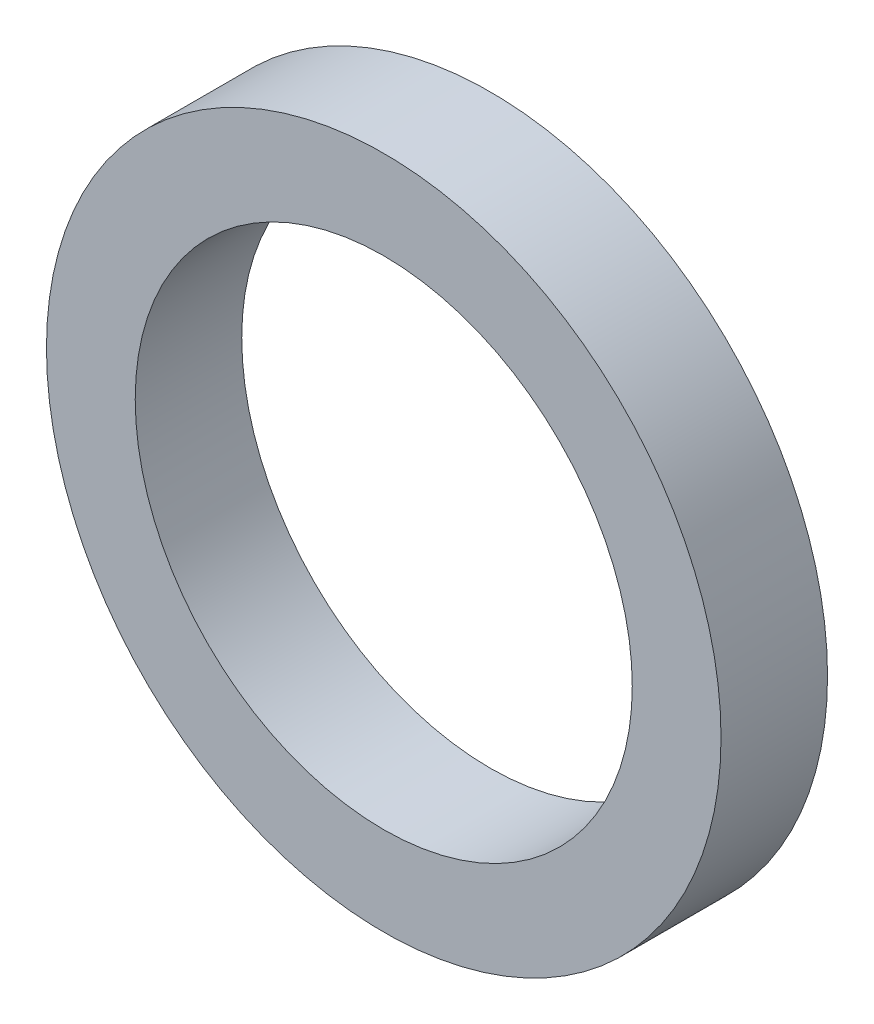
from build123d import *

# Parameters (mm, degrees)
SCHIZZO1_R                   = 9.5
SCHIZZO1_R_2                 = 7
ESTRUSIONE_ESTRUSIONE1_DEPTH = 3


with BuildPart() as part:
    # Schizzo1 → Estrusione-Estrusione1 (new body)
    with BuildSketch(Plane.XY):
        Circle(SCHIZZO1_R)
        Circle(SCHIZZO1_R_2, mode=Mode.SUBTRACT)
    extrude(amount=ESTRUSIONE_ESTRUSIONE1_DEPTH)


solid = part.part
